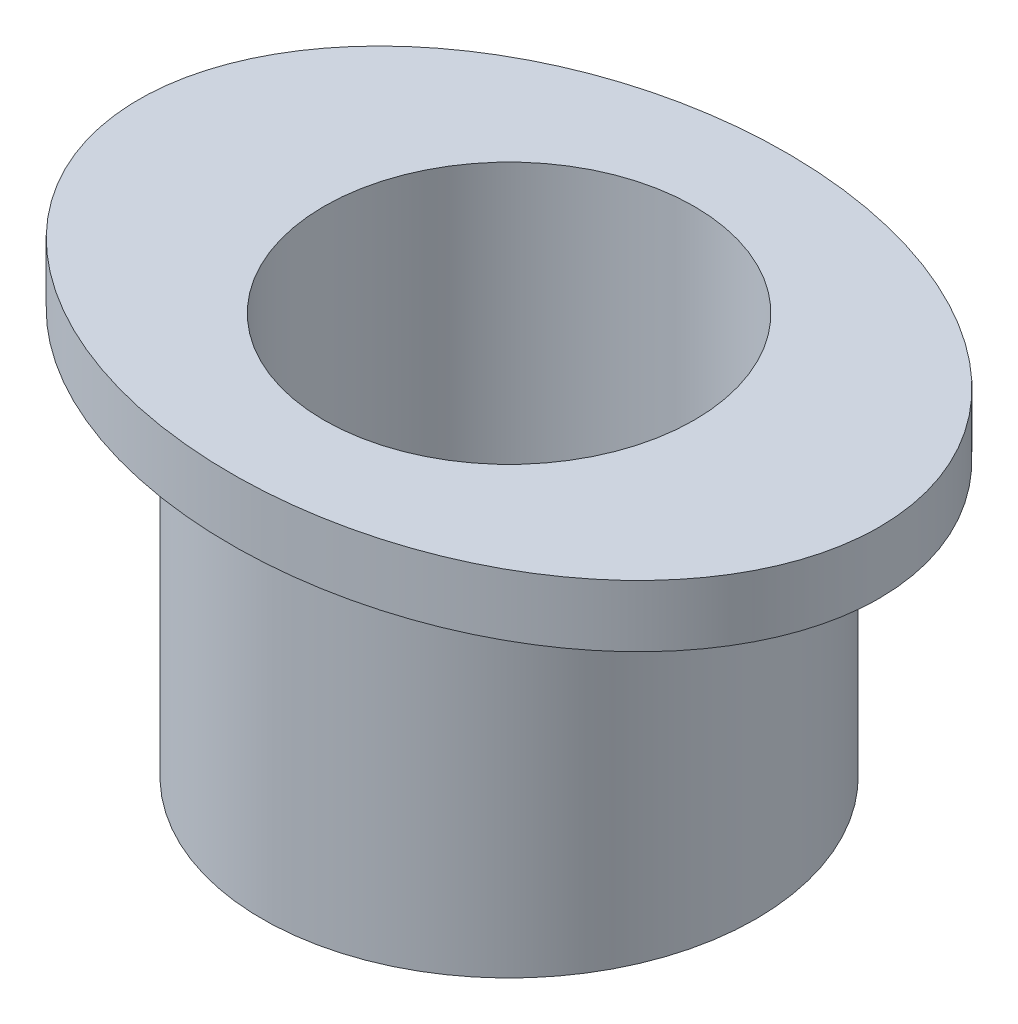
from build123d import *

# Parameters (mm, degrees)
SKETCH1_R           = 4
SKETCH1_R_2         = 3
EXTRUDE_THIN1_DEPTH = 5.5
SKETCH2_RX          = 6
SKETCH2_RY          = 4.5
SKETCH2_R           = 3
BOSS_EXTRUDE1_DEPTH = 1


with BuildPart() as part:
    # Sketch1 → Extrude-Thin1 (new body)
    with BuildSketch(Plane(origin=(0, 0, 0), x_dir=(1, 0, 0), z_dir=(0, 1, 0))):
        Circle(SKETCH1_R)
        Circle(SKETCH1_R_2, mode=Mode.SUBTRACT)
    extrude(amount=-EXTRUDE_THIN1_DEPTH)

    # Sketch2 → Boss-Extrude1 (add)
    with BuildSketch(Plane(origin=(0, 0, 0), x_dir=(1, 0, 0), z_dir=(0, 1, 0))):
        with Locations(Location((0, 0), (0, 0, 0))):
            Ellipse(SKETCH2_RX, SKETCH2_RY)
        Circle(SKETCH2_R, mode=Mode.SUBTRACT)
    extrude(amount=BOSS_EXTRUDE1_DEPTH)


solid = part.part
